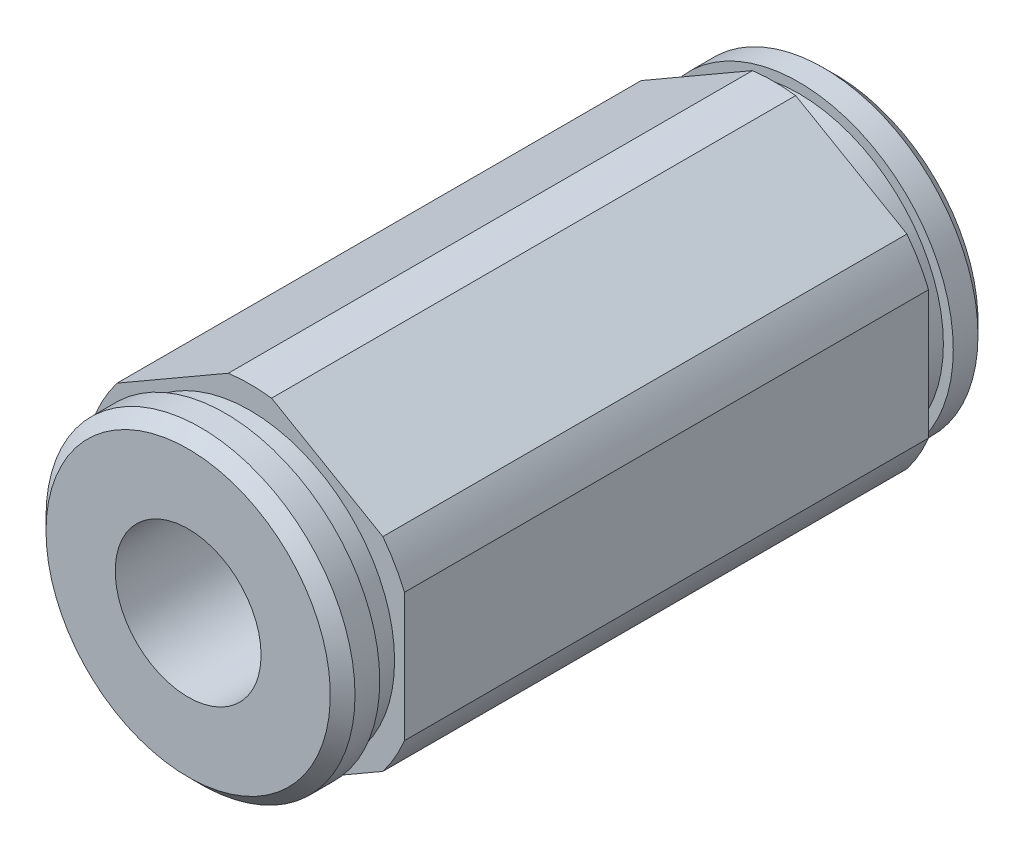
from build123d import *

# Parameters (mm, degrees)
SKETCH1_R               = 6.35
BASIC_ROD_DEPTH         = 10.7696
BASIC_ROD_DEPTH_BACK    = 10.7696
THEX_DEPTH              = 10.7696
SKETCH2_R               = 2.9972
INTERNAL_CUT_DEPTH      = 14.3096
INTERNAL_CUT_DEPTH_BACK = 14.3096


with BuildPart() as part:
    # Sketch1 → Basic Rod (new body, two sides)
    with BuildSketch(Plane.XY) as basic_rod_sk:
        Circle(SKETCH1_R)
    extrude(amount=BASIC_ROD_DEPTH)
    extrude(basic_rod_sk.sketch, amount=-BASIC_ROD_DEPTH_BACK)

    # Sketch8 → THex (add, symmetric)
    with BuildSketch(Plane.XY):
        with BuildLine():
            Line((-0.888411378, 6.819423871), (-5.461588622, 4.179098758))
            ThreePointArc((-5.461588622, 4.179098758), (-5.955700003, 3.438525), (-6.35, 2.640325113))
            Line((-6.35, 2.640325113), (-6.35, -2.640325113))
            ThreePointArc((-6.35, -2.640325113), (-5.955700003, -3.438525), (-5.461588622, -4.179098758))
            Line((-5.461588622, -4.179098758), (-0.888411378, -6.819423871))
            ThreePointArc((-0.888411378, -6.819423871), (0, -6.87705), (0.888411378, -6.819423871))
            Line((0.888411378, -6.819423871), (5.461588622, -4.179098758))
            ThreePointArc((5.461588622, -4.179098758), (5.955700003, -3.438525), (6.35, -2.640325113))
            Line((6.35, -2.640325113), (6.35, 2.640325113))
            ThreePointArc((6.35, 2.640325113), (5.955700003, 3.438525), (5.461588622, 4.179098758))
            Line((5.461588622, 4.179098758), (0.888411378, 6.819423871))
            ThreePointArc((0.888411378, 6.819423871), (0, 6.87705), (-0.888411378, 6.819423871))
        make_face()
    extrude(amount=THEX_DEPTH, both=True)

    # Sketch7 → 1stSnapRing (revolve)
    with BuildSketch(Plane(origin=(0, 0, 0), x_dir=(0, 0, -1), z_dir=(1, 0, 0))):
        Polygon((-10.7696, 5.9436), (-11.7856, 5.9436), (-11.7856, 6.35), (-12.8016, 6.35), (-13.3096, 5.842), (-13.3096, 0), (-10.7696, 0), align=None)
    f_1stsnapring = revolve(axis=Axis((0, 0, -38.2778), (0, 0, 1)))

    # 2ndSnapRing: 1stSnapRing across plane
    add(f_1stsnapring.mirror(Plane.XY))

    # Sketch2 → Internal Cut (cut, two sides)
    with BuildSketch(Plane.XY) as internal_cut_sk:
        Circle(SKETCH2_R)
    extrude(amount=INTERNAL_CUT_DEPTH, mode=Mode.SUBTRACT)
    extrude(internal_cut_sk.sketch, amount=-INTERNAL_CUT_DEPTH_BACK, mode=Mode.SUBTRACT)


solid = part.part
